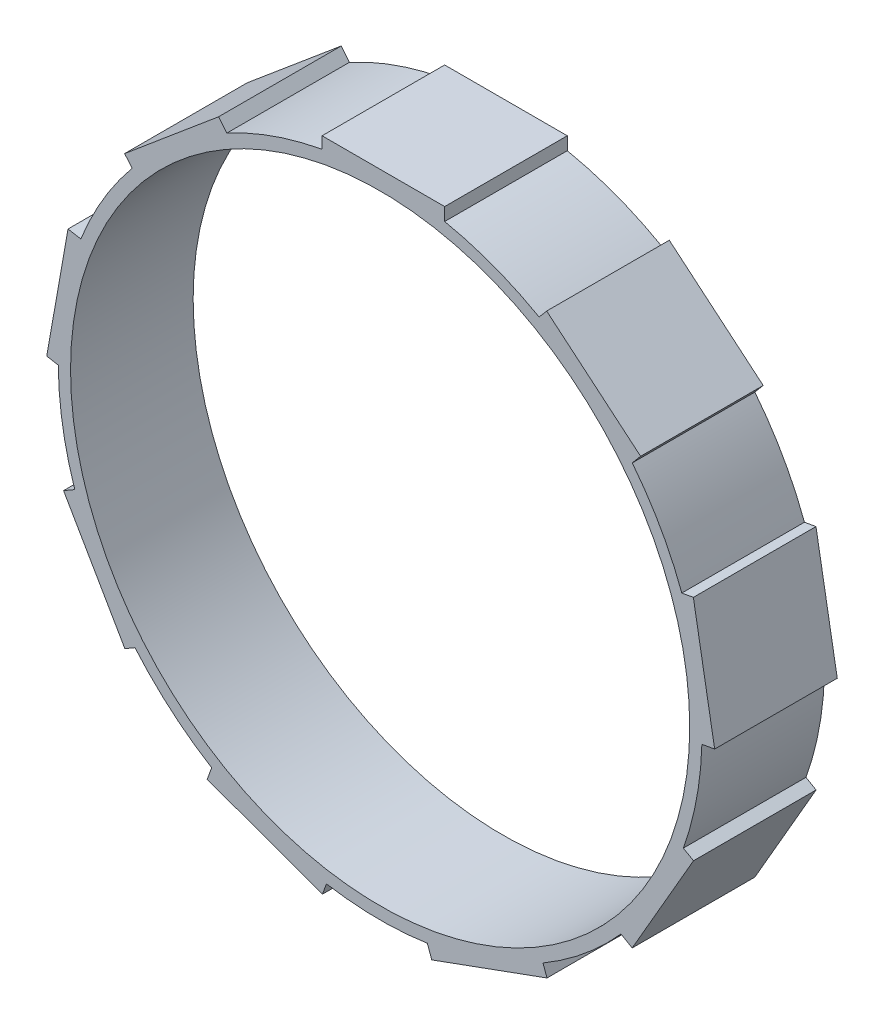
from build123d import *

# Parameters (mm, degrees)
CROQUIS1_R              = 25.25
SALIENTE_EXTRUIR1_DEPTH = 10


with BuildPart() as part:
    # Croquis1 → Saliente-Extruir1 (new body)
    with BuildSketch(Plane.XY):
        with BuildLine():
            Line((12.967631227, 22.823300382), (13.581702718, 23.555122287))
            Line((13.581702718, 23.555122287), (21.242147149, 17.12724619))
            Line((21.242147149, 17.12724619), (20.562408201, 16.317164857))
            ThreePointArc((20.562408201, 16.317164857), (22.866059206, 12.892084254), (24.60431654, 9.148229752))
            Line((24.60431654, 9.148229752), (25.545128646, 9.31412031))
            Line((25.545128646, 9.31412031), (27.281610423, -0.53395722))
            Line((27.281610423, -0.53395722), (26.240189935, -0.717587751))
            ThreePointArc((26.240189935, -0.717587751), (25.803289612, -4.822110037), (24.728368697, -8.807399251))
            Line((24.728368697, -8.807399251), (25.555704978, -9.285062076))
            Line((25.555704978, -9.285062076), (20.555704978, -17.945316114))
            Line((20.555704978, -17.945316114), (19.639895171, -17.416573075))
            ThreePointArc((19.639895171, -17.416573075), (16.666874037, -20.27998545), (13.281742316, -22.641948261))
            Line((13.281742316, -22.641948261), (13.608482931, -23.539660724))
            Line((13.608482931, -23.539660724), (4.211556723, -26.959862157))
            Line((4.211556723, -26.959862157), (3.849875184, -25.966150294))
            ThreePointArc((3.849875184, -25.966150294), (-0.268157132, -26.248630283), (-4.379558905, -25.882078042))
            Line((-4.379558905, -25.882078042), (-4.706299521, -26.779790505))
            Line((-4.706299521, -26.779790505), (-14.103225729, -23.359589072))
            Line((-14.103225729, -23.359589072), (-13.741544189, -22.365877208))
            ThreePointArc((-13.741544189, -22.365877208), (-17.077714598, -19.935249286), (-19.991615841, -17.01169586))
            Line((-19.991615841, -17.01169586), (-20.818952122, -17.489358685))
            Line((-20.818952122, -17.489358685), (-25.818952122, -8.829104647))
            Line((-25.818952122, -8.829104647), (-24.903142315, -8.300361608))
            ThreePointArc((-24.903142315, -8.300361608), (-25.896419606, -4.293943593), (-26.249373543, -0.181352121))
            Line((-26.249373543, -0.181352121), (-27.190185649, -0.015461563))
            Line((-27.190185649, -0.015461563), (-25.453703872, 9.832615967))
            Line((-25.453703872, 9.832615967), (-24.412283385, 9.648985436))
            ThreePointArc((-24.412283385, 9.648985436), (-22.597902074, 13.35654603), (-20.224757635, 16.733848291))
            Line((-20.224757635, 16.733848291), (-20.838829125, 17.465670196))
            Line((-20.838829125, 17.465670196), (-13.178384694, 23.893546292))
            Line((-13.178384694, 23.893546292), (-12.498645746, 23.083464959))
            ThreePointArc((-12.498645746, 23.083464959), (-8.725575014, 24.757359324), (-4.736752856, 25.819095112))
            Line((-4.736752856, 25.819095112), (-4.736752856, 26.774420761))
            Line((-4.736752856, 26.774420761), (5.263247144, 26.774420761))
            Line((5.263247144, 26.774420761), (5.263247144, 25.716934683))
            ThreePointArc((5.263247144, 25.716934683), (9.229545569, 24.573929042), (12.967631227, 22.823300382))
        make_face()
        Circle(CROQUIS1_R, mode=Mode.SUBTRACT)
    extrude(amount=SALIENTE_EXTRUIR1_DEPTH)


solid = part.part
